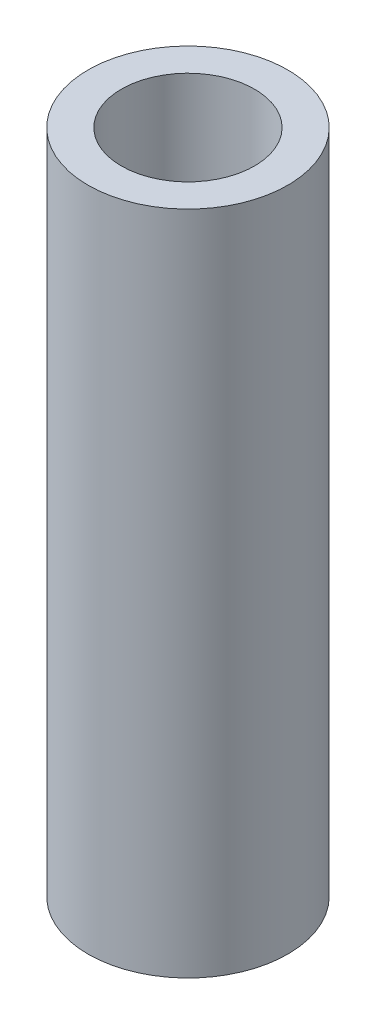
from build123d import *

# Parameters (mm, degrees)
SKETCH1_R           = 3
BOSS_EXTRUDE1_DEPTH = 20
SKETCH2_R           = 2
CUT_EXTRUDE1_DEPTH  = 21


with BuildPart() as part:
    # Sketch1 → Boss-Extrude1 (new body)
    with BuildSketch(Plane(origin=(0, 0, 0), x_dir=(1, 0, 0), z_dir=(0, 1, 0))):
        Circle(SKETCH1_R)
    extrude(amount=BOSS_EXTRUDE1_DEPTH)

    # Sketch2 → Cut-Extrude1 (cut, through all)
    with BuildSketch(Plane(origin=(0, 20, 0), x_dir=(1, 0, 0), z_dir=(0, 1, 0))):
        Circle(SKETCH2_R)
    extrude(amount=-CUT_EXTRUDE1_DEPTH, mode=Mode.SUBTRACT)


solid = part.part
